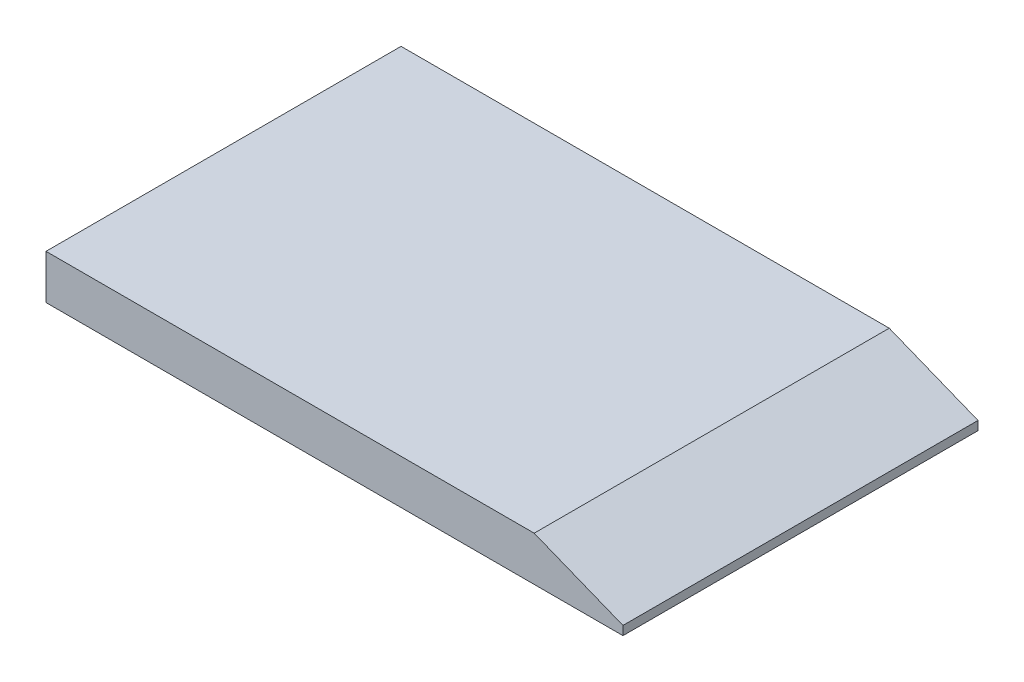
from build123d import *

# Parameters (mm, degrees)
SKETCH1_W           = 130
SKETCH1_H           = 80
BOSS_EXTRUDE1_DEPTH = 10
CUT_EXTRUDE1_DEPTH  = 81


with BuildPart() as part:
    # Sketch1 → Boss-Extrude1 (new body)
    with BuildSketch(Plane(origin=(0, 0, 0), x_dir=(1, 0, 0), z_dir=(0, 1, 0))):
        Rectangle(SKETCH1_W, SKETCH1_H)
    extrude(amount=BOSS_EXTRUDE1_DEPTH)

    # Sketch2 → Cut-Extrude1 (cut, through all)
    with BuildSketch(Plane.XY.offset(40)):
        Polygon((65, 2), (45, 10), (65, 10), align=None)
    extrude(amount=-CUT_EXTRUDE1_DEPTH, mode=Mode.SUBTRACT)


solid = part.part
